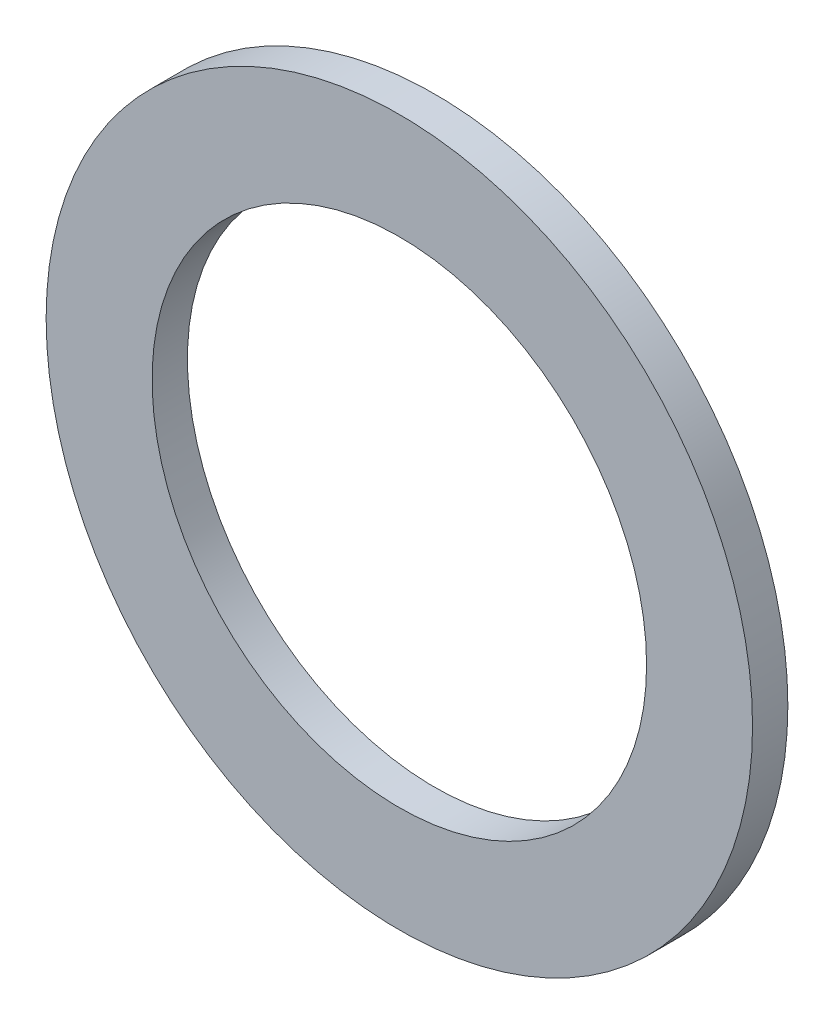
from build123d import *

# Parameters (mm, degrees)
SKETCH1_R           = 31.75
SKETCH1_R_2         = 22.225
BOSS_EXTRUDE1_DEPTH = 3.175


with BuildPart() as part:
    # Sketch1 → Boss-Extrude1 (new body)
    with BuildSketch(Plane.XY):
        Circle(SKETCH1_R)
        Circle(SKETCH1_R_2, mode=Mode.SUBTRACT)
    extrude(amount=BOSS_EXTRUDE1_DEPTH)


solid = part.part
